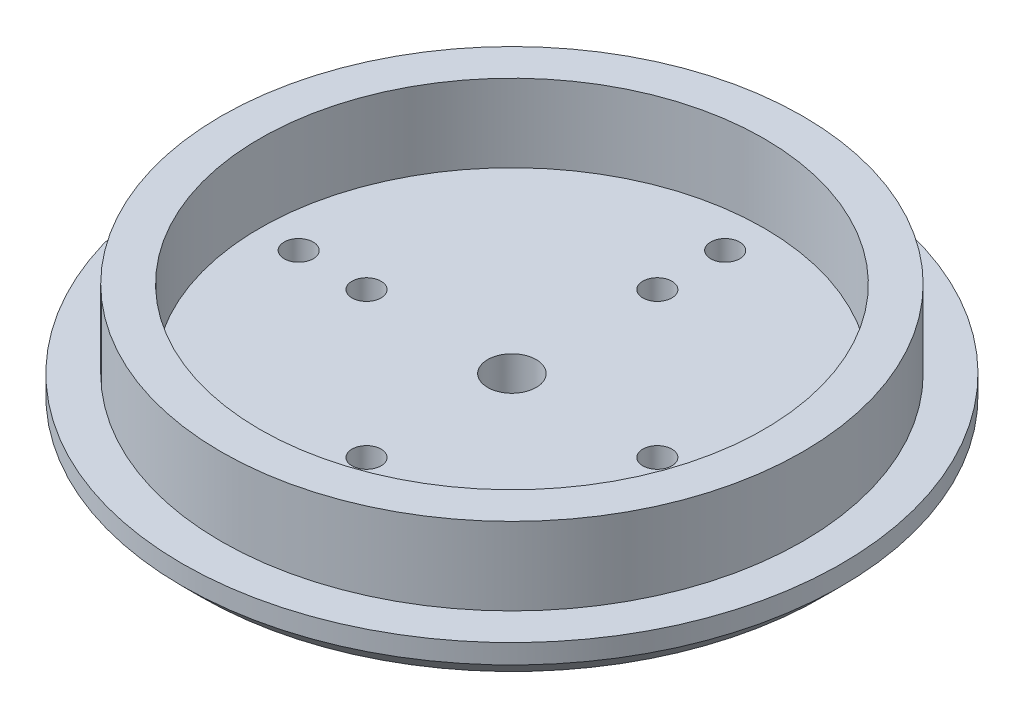
from build123d import *

# Parameters (mm, degrees)
SKETCH_1_R          = 34
EXTRUDE_1_DEPTH     = 4
SKETCH_2_R          = 30
SKETCH_2_R_2        = 26
EXTRUDE_2_DEPTH     = 8
SKETCH_3_R          = 2.5
SKETCH_3_R_2        = 1.5
CUT_EXTRUDE_1_DEPTH = 13
SKETCH_4_R          = 6
SKETCH_4_R_2        = 2.5
EXTRUDE_3_DEPTH     = 1
CHAMFER_1_SIZE      = 2
EXTRUDE_4_DEPTH     = 1


with BuildPart() as part:
    # 草图1 → 凸台-拉伸1 (new body)
    with BuildSketch(Plane(origin=(0, 0, 0), x_dir=(1, 0, 0), z_dir=(0, 1, 0))):
        Circle(SKETCH_1_R)
    extrude(amount=EXTRUDE_1_DEPTH)

    # 草图2 → 凸台-拉伸2 (add)
    with BuildSketch(Plane(origin=(0, 4, 0), x_dir=(1, 0, 0), z_dir=(0, 1, 0))):
        Circle(SKETCH_2_R)
        Circle(SKETCH_2_R_2, mode=Mode.SUBTRACT)
    extrude(amount=EXTRUDE_2_DEPTH)

    # 草图3 → 切除-拉伸1 (cut, through all)
    with BuildSketch(Plane.XZ):
        Circle(SKETCH_3_R)
        with Locations((0, 15)):
            Circle(SKETCH_3_R_2)
        with Locations((0, 22)):
            Circle(SKETCH_3_R_2)
        with Locations((15, 0)):
            Circle(SKETCH_3_R_2)
        with Locations((22, 0)):
            Circle(SKETCH_3_R_2)
        with Locations((0, -15)):
            Circle(SKETCH_3_R_2)
        with Locations((0, -22)):
            Circle(SKETCH_3_R_2)
        with Locations((-15, 0)):
            Circle(SKETCH_3_R_2)
        with Locations((-22, 0)):
            Circle(SKETCH_3_R_2)
    extrude(amount=-CUT_EXTRUDE_1_DEPTH, mode=Mode.SUBTRACT)

    # 草图4 → 凸台-拉伸3 (add)
    with BuildSketch(Plane.XZ):
        Circle(SKETCH_4_R)
        Circle(SKETCH_4_R_2, mode=Mode.SUBTRACT)
    extrude(amount=EXTRUDE_3_DEPTH)

    # 倒角1
    chamfer_1_edges = [part.edges().sort_by_distance(p)[0] for p in [
        (-34, 0, 0),
    ]]
    chamfer(chamfer_1_edges, length=CHAMFER_1_SIZE)

    # 草图5 → 凸台-拉伸4 (add)
    with BuildSketch(Plane.XZ):
        with BuildLine():
            Line((-19.445436483, -18.03122292), (-17.324116139, -15.909902577))
            ThreePointArc((-17.324116139, -15.909902577), (-15.909902577, -15.909902577), (-15.909902577, -17.324116139))
            Line((-15.909902577, -17.324116139), (-18.03122292, -19.445436483))
            ThreePointArc((-18.03122292, -19.445436483), (-19.445436483, -19.445436483), (-19.445436483, -18.03122292))
        make_face()
        with BuildLine():
            Line((-13.081475452, -20.152543264), (-15.202795796, -22.273863607))
            ThreePointArc((-15.202795796, -22.273863607), (-16.617009358, -22.273863607), (-16.617009358, -20.859650045))
            Line((-16.617009358, -20.859650045), (-14.495689014, -18.738329701))
            ThreePointArc((-14.495689014, -18.738329701), (-13.081475452, -18.738329701), (-13.081475452, -20.152543264))
        make_face()
        with BuildLine():
            Line((-20.152543264, -13.081475452), (-22.273863607, -15.202795796))
            ThreePointArc((-22.273863607, -15.202795796), (-22.273863607, -16.617009358), (-20.859650045, -16.617009358))
            Line((-20.859650045, -16.617009358), (-18.738329701, -14.495689014))
            ThreePointArc((-18.738329701, -14.495689014), (-18.738329701, -13.081475452), (-20.152543264, -13.081475452))
        make_face()
    extrude(amount=EXTRUDE_4_DEPTH)


solid = part.part
